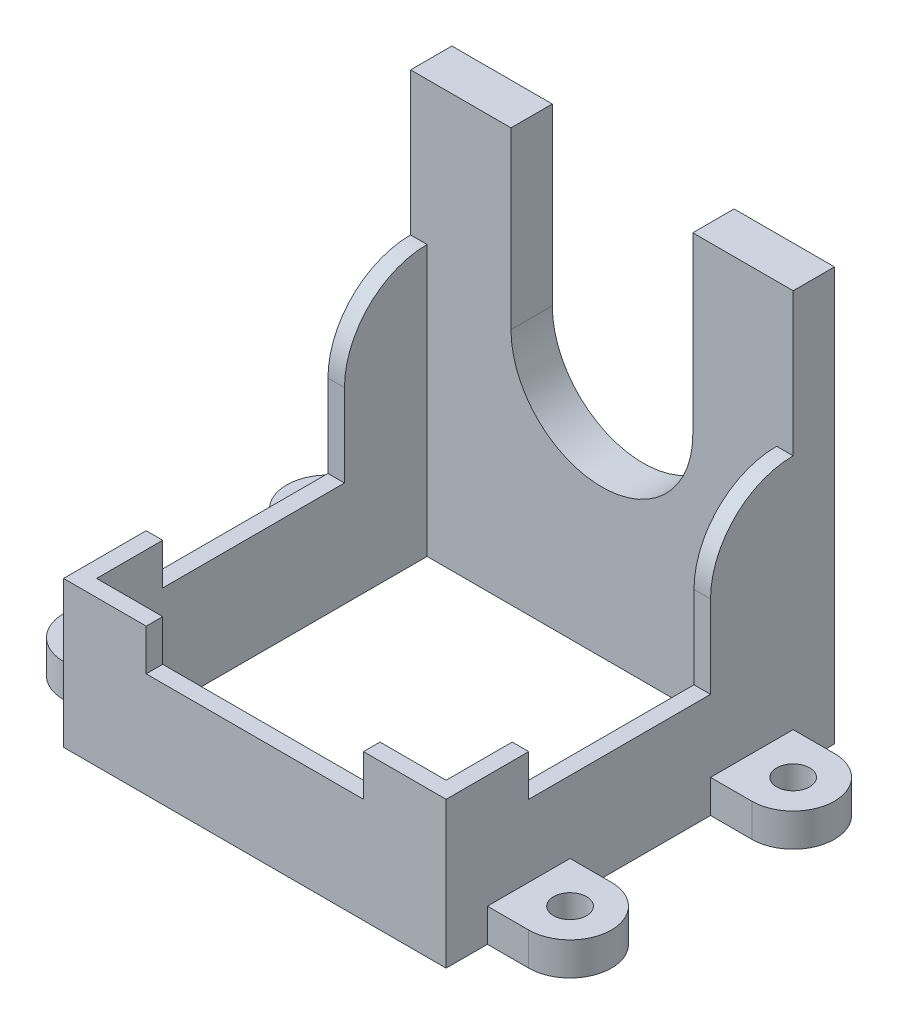
from build123d import *

# Parameters (mm, degrees)
SKETCH_1_W          = 46.3
SKETCH_1_H          = 47
EXTRUDE_1_DEPTH     = 50
SKETCH_2_W          = 46.3
SKETCH_2_H          = 42
CUT_EXTRUDE_1_DEPTH = 32.3
SKETCH_3_W          = 42.3
SKETCH_3_H          = 40
CUT_EXTRUDE_2_DEPTH = 10
SKETCH_4_W          = 42.3
SKETCH_4_H          = 37
CUT_EXTRUDE_3_DEPTH = 8.7
SKETCH_5_W          = 2
SKETCH_5_H          = 22
SKETCH_5_W_2        = 26.3
SKETCH_5_H_2        = 2
CUT_EXTRUDE_4_DEPTH = 5
SKETCH_7_W          = 10
SKETCH_7_H          = 5
EXTRUDE_2_DEPTH     = 2
SKETCH_8_W          = 10
SKETCH_8_H          = 5
EXTRUDE_3_DEPTH     = 2
SKETCH_9_W          = 22
SKETCH_9_H          = 21.15
CUT_EXTRUDE_5_DEPTH = 6
SKETCH_11_R         = 2
EXTRUDE_4_DEPTH     = 4
SKETCH_12_R         = 2
CUT_EXTRUDE_6_DEPTH = 4
SCALE_1_SCALE       = 1.015


with BuildPart() as part:
    # 草圖1 → 填料-伸長1 (new body)
    with BuildSketch(Plane(origin=(0, 0, 0), x_dir=(1, 0, 0), z_dir=(0, 1, 0))):
        with Locations((23.15, 23.5)):
            Rectangle(SKETCH_1_W, SKETCH_1_H)
    extrude(amount=EXTRUDE_1_DEPTH)

    # 草圖2 → 除料-伸長1 (cut)
    with BuildSketch(Plane(origin=(0, 50, 0), x_dir=(1, 0, 0), z_dir=(0, 1, 0))):
        with Locations((23.15, 21)):
            Rectangle(SKETCH_2_W, SKETCH_2_H)
    extrude(amount=-CUT_EXTRUDE_1_DEPTH, mode=Mode.SUBTRACT)

    # 草圖3 → 除料-伸長2 (cut)
    with BuildSketch(Plane(origin=(0, 17.7, 0), x_dir=(1, 0, 0), z_dir=(0, 1, 0))):
        with Locations((23.15, 22)):
            Rectangle(SKETCH_3_W, SKETCH_3_H)
    extrude(amount=-CUT_EXTRUDE_2_DEPTH, mode=Mode.SUBTRACT)

    # 草圖4 → 除料-伸長3 (cut, through all)
    with BuildSketch(Plane(origin=(0, 7.7, 0), x_dir=(1, 0, 0), z_dir=(0, 1, 0))):
        with Locations((23.15, 23.5)):
            Rectangle(SKETCH_4_W, SKETCH_4_H)
    extrude(amount=-CUT_EXTRUDE_3_DEPTH, mode=Mode.SUBTRACT)

    # 草圖5 → 除料-伸長4 (cut)
    with BuildSketch(Plane(origin=(0, 17.7, 0), x_dir=(1, 0, 0), z_dir=(0, 1, 0))):
        with Locations((1, 21)):
            Rectangle(SKETCH_5_W, SKETCH_5_H)
        with Locations((45.3, 21)):
            Rectangle(SKETCH_5_W, SKETCH_5_H)
        with Locations((23.15, 1)):
            Rectangle(SKETCH_5_W_2, SKETCH_5_H_2)
    extrude(amount=-CUT_EXTRUDE_4_DEPTH, mode=Mode.SUBTRACT)

    # 草圖7 → 填料-伸長2 (add)
    with BuildSketch(Plane.ZY):
        with BuildLine():
            Line((-42, 32.7), (-42, 22.7))
            Line((-42, 22.7), (-32, 22.7))
            ThreePointArc((-32, 22.7), (-34.928932188, 29.771067812), (-42, 32.7))
        make_face()
        with Locations((-37, 20.2)):
            Rectangle(SKETCH_7_W, SKETCH_7_H)
    extrude(amount=-EXTRUDE_2_DEPTH)

    # 草圖8 → 填料-伸長3 (add)
    with BuildSketch(Plane(origin=(46.3, 0, 0), x_dir=(0, 0, -1), z_dir=(1, 0, 0))):
        with Locations((37, 20.2)):
            Rectangle(SKETCH_8_W, SKETCH_8_H)
        with BuildLine():
            Line((32, 22.7), (42, 22.7))
            Line((42, 22.7), (42, 32.7))
            ThreePointArc((42, 32.7), (34.928932188, 29.771067812), (32, 22.7))
        make_face()
    extrude(amount=-EXTRUDE_3_DEPTH)

    # 草圖9 → 除料-伸長5 (cut, through all)
    with BuildSketch(Plane.XY.offset(-42)):
        with BuildLine():
            ThreePointArc((34.15, 28.85), (23.15, 17.85), (12.15, 28.85))
            Line((12.15, 28.85), (34.15, 28.85))
        make_face()
        with Locations((23.15, 39.425)):
            Rectangle(SKETCH_9_W, SKETCH_9_H)
    extrude(amount=-CUT_EXTRUDE_5_DEPTH, mode=Mode.SUBTRACT)

    # 草圖11 → 填料-伸長4 (add)
    with BuildSketch(Plane.XZ):
        with BuildLine():
            Line((51.3, -5), (46.3, -5))
            Line((46.3, -5), (46.3, -15))
            Line((46.3, -15), (51.3, -15))
            ThreePointArc((51.3, -15), (56.3, -10), (51.3, -5))
        make_face()
        with Locations((51.3, -10)):
            Circle(SKETCH_11_R, mode=Mode.SUBTRACT)
        with BuildLine():
            Line((46.3, -32), (46.3, -42))
            Line((46.3, -42), (51.3, -42))
            ThreePointArc((51.3, -42), (56.3, -37), (51.3, -32))
            Line((51.3, -32), (46.3, -32))
        make_face()
        with Locations((51.3, -37)):
            Circle(SKETCH_11_R, mode=Mode.SUBTRACT)
        with BuildLine():
            Line((0, -15), (0, -5))
            Line((0, -5), (-5, -5))
            ThreePointArc((-5, -5), (-10, -10), (-5, -15))
            Line((-5, -15), (0, -15))
        make_face()
        with BuildLine():
            Line((0, -42), (0, -32))
            Line((0, -32), (-5, -32))
            ThreePointArc((-5, -32), (-10, -37), (-5, -42))
            Line((-5, -42), (0, -42))
        make_face()
        with Locations((-5, -37)):
            Circle(SKETCH_11_R, mode=Mode.SUBTRACT)
    extrude(amount=-EXTRUDE_4_DEPTH)

    # 草圖12 → 除料-伸長6 (cut)
    with BuildSketch(Plane.XZ):
        with Locations((-5, -10)):
            Circle(SKETCH_12_R)
    extrude(amount=-CUT_EXTRUDE_6_DEPTH, mode=Mode.SUBTRACT)


with BuildPart() as part_1:
    # 縮放比例1: scaled about (23.15, 15.034187995, -32.143313771)
    add(part.part.scale(SCALE_1_SCALE).moved(Location((-0.34725, -0.22551282, 0.482149707))))


solid = part_1.part
